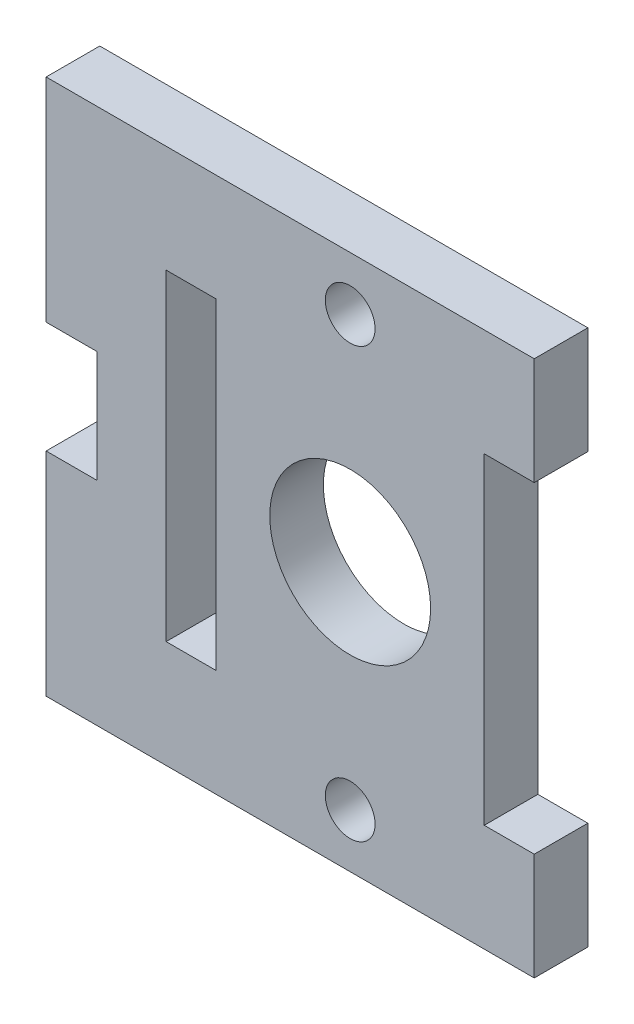
from build123d import *

# Parameters (mm, degrees)
BOSS_EXTRUDE1_DEPTH       = 3.175
F_4_CLEARANCE_HOLE1_D     = 2.9464
F_4_CLEARANCE_HOLE1_DEPTH = 3.302
F_4_CLEARANCE_HOLE1_TIP   = 0.885187864
CUT_EXTRUDE1_REACH        = 5.175
SKETCH4_R                 = 4.7625
BOSS_EXTRUDE2_DEPTH       = 3.175


with BuildPart() as part:
    # Sketch1 → Boss-Extrude1 (new body)
    with BuildSketch(Plane.XY):
        Polygon((7.9375, -3.175), (10.8966, -3.175), (10.8966, 3.175), (-10.8966, 3.175), (-10.8966, -3.175), (-7.9375, -3.175), (-7.9375, -22.225), (-10.8966, -22.225), (-10.8966, -28.575), (10.8966, -28.575), (10.8966, -22.225), (7.9375, -22.225), align=None)
    extrude(amount=BOSS_EXTRUDE1_DEPTH)

    # #4 Clearance Hole1
    with Locations(Plane.XY.offset(3.175)):
        with Locations((0, 0), (0, -25.4)):
            Hole(F_4_CLEARANCE_HOLE1_D / 2, depth=F_4_CLEARANCE_HOLE1_DEPTH)
            with Locations((0, 0, -(F_4_CLEARANCE_HOLE1_DEPTH + F_4_CLEARANCE_HOLE1_TIP / 2))):  # 118° drill point
                Cone(0, F_4_CLEARANCE_HOLE1_D / 2, F_4_CLEARANCE_HOLE1_TIP, mode=Mode.SUBTRACT)

    # Sketch4 → Cut-Extrude1 (cut, up to next)
    with BuildSketch(Plane.XY.offset(3.175), mode=Mode.PRIVATE) as cut_extrude1_sk1:
        with Locations((0, -12.7)):
            Circle(SKETCH4_R)
    cut_extrude1_tool1 = extrude(cut_extrude1_sk1.sketch, amount=-CUT_EXTRUDE1_REACH, mode=Mode.PRIVATE) & part.part
    add(cut_extrude1_tool1.solids().sort_by_distance((0, -12.7, 3.175))[0], mode=Mode.SUBTRACT)

    # Sketch5 → Boss-Extrude2 (add)
    with BuildSketch(Plane.XY.offset(3.175)):
        Polygon((-10.8966, -3.175), (-10.8966, -22.225), (-10.8966, -28.575), (-18, -28.575), (-18, -16.002), (-15, -16.002), (-15, -9.398), (-18, -9.398), (-18, 3.175), (-10.8966, 3.175), align=None)
    extrude(amount=-BOSS_EXTRUDE2_DEPTH)


solid = part.part
